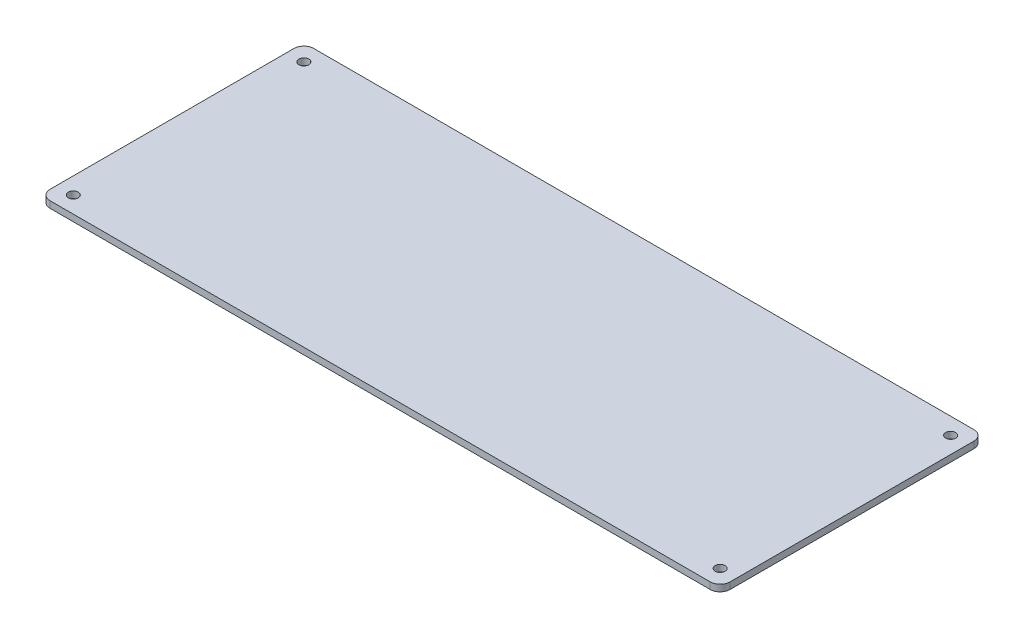
from build123d import *

# Parameters (mm, degrees)
SKETCH1_W           = 205
SKETCH1_H           = 79.5
BOSS_EXTRUDE1_DEPTH = 2
SKETCH2_R           = 1.5
CUT_EXTRUDE1_DEPTH  = 2
FILLET1_R           = 3
FILLET3_R           = 3
FILLET4_R           = 3
FILLET5_R           = 3


with BuildPart() as part:
    # Sketch1 → Boss-Extrude1 (new body)
    with BuildSketch(Plane(origin=(0, 0, 0), x_dir=(1, 0, 0), z_dir=(0, 1, 0))):
        Rectangle(SKETCH1_W, SKETCH1_H)
    extrude(amount=BOSS_EXTRUDE1_DEPTH)

    # Sketch2 → Cut-Extrude1 (cut)
    with BuildSketch(Plane(origin=(0, 2, 0), x_dir=(1, 0, 0), z_dir=(0, 1, 0))):
        with Locations((-97.5, 34.75)):
            Circle(SKETCH2_R)
        with Locations((-97.5, -34.75)):
            Circle(SKETCH2_R)
        with Locations((97.5, -34.75)):
            Circle(SKETCH2_R)
        with Locations((97.5, 34.75)):
            Circle(SKETCH2_R)
    extrude(amount=-CUT_EXTRUDE1_DEPTH, mode=Mode.SUBTRACT)

    # Fillet1
    fillet1_edges = [part.edges().sort_by_distance(p)[0] for p in [
        (-102.5, 1, 39.75),
    ]]
    fillet(fillet1_edges, radius=FILLET1_R)

    # Fillet3
    fillet3_edges = [part.edges().sort_by_distance(p)[0] for p in [
        (102.5, 1, 39.75),
    ]]
    fillet(fillet3_edges, radius=FILLET3_R)

    # Fillet4
    fillet4_edges = [part.edges().sort_by_distance(p)[0] for p in [
        (102.5, 1, -39.75),
    ]]
    fillet(fillet4_edges, radius=FILLET4_R)

    # Fillet5
    fillet5_edges = [part.edges().sort_by_distance(p)[0] for p in [
        (-102.5, 1, -39.75),
    ]]
    fillet(fillet5_edges, radius=FILLET5_R)


solid = part.part
